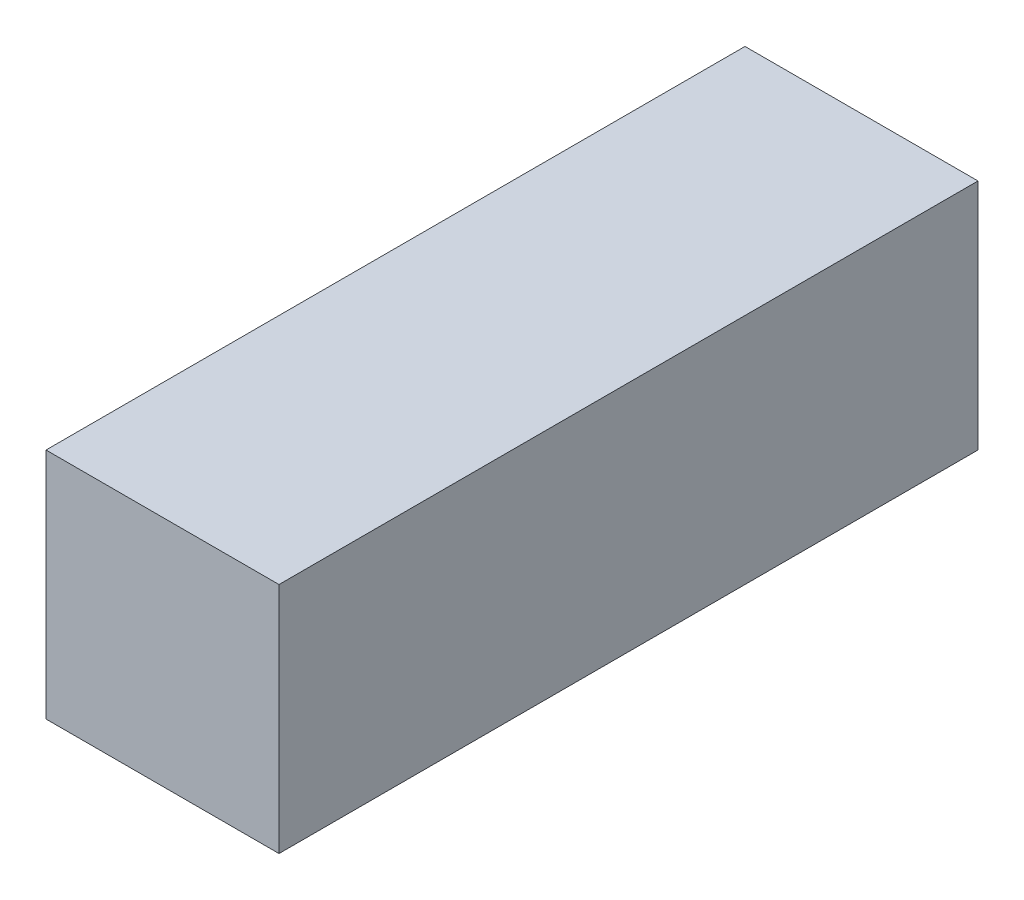
from build123d import *

# Parameters (mm, degrees)
SKETCH1_W           = 200
SKETCH1_H           = 600
BOSS_EXTRUDE1_DEPTH = 200


with BuildPart() as part:
    # Sketch1 → Boss-Extrude1 (new body)
    with BuildSketch(Plane(origin=(0, 0, 0), x_dir=(1, 0, 0), z_dir=(0, 1, 0))):
        with Locations((42.495842889, -40.961865339)):
            Rectangle(SKETCH1_W, SKETCH1_H)
    extrude(amount=BOSS_EXTRUDE1_DEPTH)


solid = part.part
